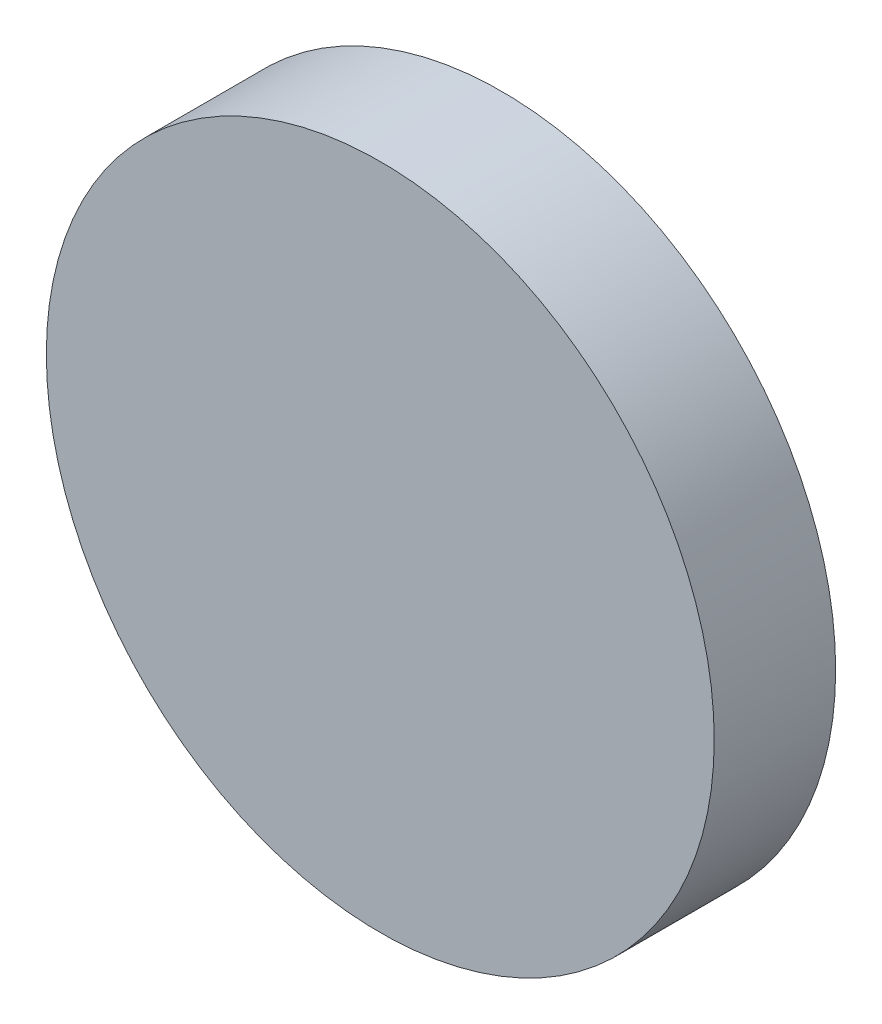
from build123d import *

# Parameters (mm, degrees)
SKETCH1_R           = 139.7
BOSS_EXTRUDE1_DEPTH = 25.4


with BuildPart() as part:
    # Sketch1 → Boss-Extrude1 (new body, symmetric)
    with BuildSketch(Plane.XY):
        Circle(SKETCH1_R)
    extrude(amount=BOSS_EXTRUDE1_DEPTH, both=True)


solid = part.part
